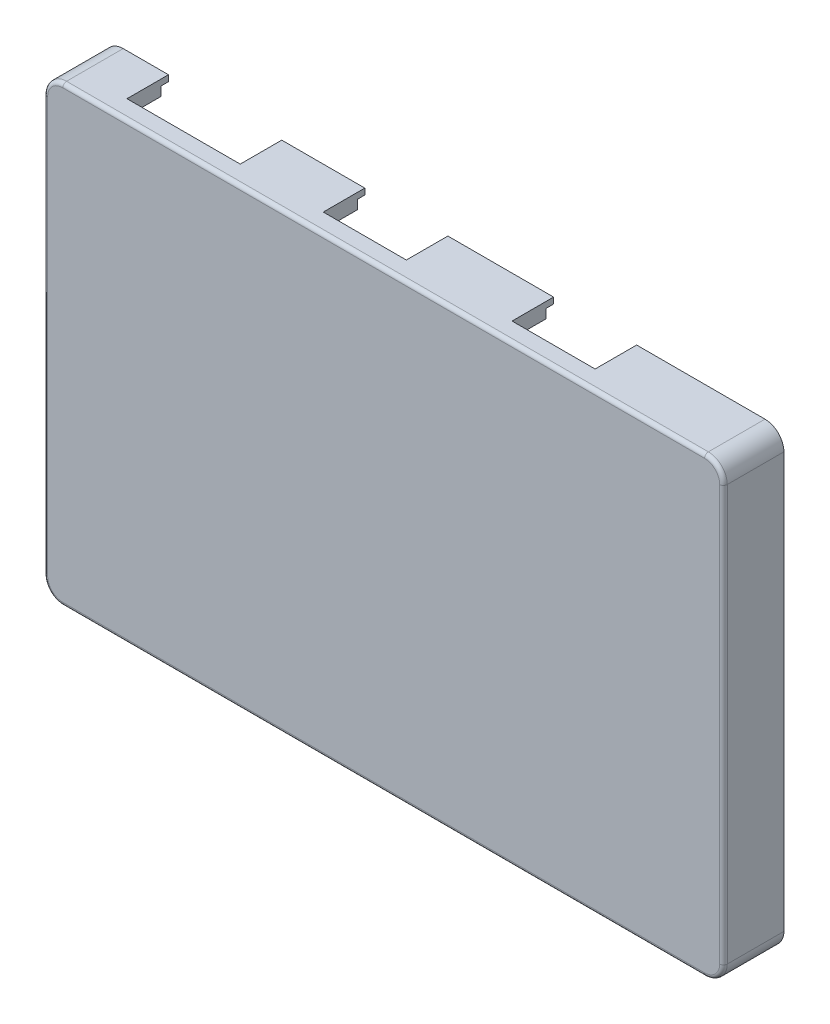
from build123d import *

# Parameters (mm, degrees)
SKETCH_1_W          = 90
SKETCH_1_H          = 60
EXTRUDE_1_DEPTH     = 2
SKETCH_2_W          = 50
SKETCH_2_H          = 35
EXTRUDE_2_DEPTH     = 1
SKETCH_3_W          = 14
SKETCH_3_H          = 13
EXTRUDE_3_DEPTH     = 10
SKETCH_4_W          = 10
SKETCH_4_H          = 12
EXTRUDE_4_DEPTH     = 5
SKETCH_5_W          = 26
SKETCH_5_H          = 26
EXTRUDE_5_DEPTH     = 1
SKETCH_6_W          = 10
SKETCH_6_H          = 10
EXTRUDE_6_DEPTH     = 7
SKETCH_7_W          = 43
SKETCH_7_H          = 18
EXTRUDE_7_DEPTH     = 1
SKETCH_8_W          = 2
SKETCH_8_H          = 60
EXTRUDE_8_DEPTH     = 5
SKETCH_9_W          = 88
SKETCH_9_H          = 2
EXTRUDE_9_DEPTH     = 5
SKETCH_10_W         = 2
SKETCH_10_H         = 58
EXTRUDE_10_DEPTH    = 5
SKETCH_11_W         = 86
SKETCH_11_H         = 2
EXTRUDE_11_DEPTH    = 5
SKETCH_12_W         = 0.8
SKETCH_12_H         = 60
EXTRUDE_12_DEPTH    = 1
SKETCH_13_W         = 89.2
SKETCH_13_H         = 0.8
EXTRUDE_13_DEPTH    = 1
SKETCH_14_W         = 0.8
SKETCH_14_H         = 59.2
EXTRUDE_14_DEPTH    = 1
SKETCH_15_W         = 88.4
SKETCH_15_H         = 0.8
EXTRUDE_15_DEPTH    = 1
SKETCH_16_W         = 11
SKETCH_16_H         = 8
CUT_EXTRUDE_2_DEPTH = 34
SKETCH_17_W         = 11
SKETCH_17_H         = 6
CUT_EXTRUDE_3_DEPTH = 34
SKETCH_18_W         = 15
SKETCH_18_H         = 11
CUT_EXTRUDE_4_DEPTH = 34
SKETCH_19_W         = 30
SKETCH_19_H         = 2
EXTRUDE_16_DEPTH    = 2
SKETCH_20_W         = 43
SKETCH_20_H         = 18
CUT_EXTRUDE_5_DEPTH = 1.5
SKETCH_21_W         = 26
SKETCH_21_H         = 26
CUT_EXTRUDE_6_DEPTH = 1.5
SKETCH_22_W         = 50
SKETCH_22_H         = 35
CUT_EXTRUDE_7_DEPTH = 1.5
FILLET_1_R          = 2.5
FILLET_2_R          = 2.5
FILLET_3_R          = 0.5


with BuildPart() as part:
    # Эскиз1 → Бобышка-Вытянуть1 (new body)
    with BuildSketch(Plane.XY):
        with Locations((11.347826087, -8.739130435)):
            Rectangle(SKETCH_1_W, SKETCH_1_H)
    extrude(amount=EXTRUDE_1_DEPTH)

    # Эскиз2 → Бобышка-Вытянуть2 (add)
    with BuildSketch(Plane(origin=(0, 0, 0), x_dir=(-1, 0, 0), z_dir=(0, 0, -1))):
        with Locations((3.652173913, 0.760869565)):
            Rectangle(SKETCH_2_W, SKETCH_2_H)
    extrude(amount=EXTRUDE_2_DEPTH)

    # Эскиз3 → Бобышка-Вытянуть3 (add)
    with BuildSketch(Plane(origin=(0, 0, -1), x_dir=(-1, 0, 0), z_dir=(0, 0, -1))):
        with Locations((17.652173913, 5.760869565)):
            Rectangle(SKETCH_3_W, SKETCH_3_H)
    extrude(amount=EXTRUDE_3_DEPTH)

    # Эскиз4 → Бобышка-Вытянуть4 (add)
    with BuildSketch(Plane(origin=(0, 0, -1), x_dir=(-1, 0, 0), z_dir=(0, 0, -1))):
        with Locations((-6.347826087, 15.260869565)):
            Rectangle(SKETCH_4_W, SKETCH_4_H)
    extrude(amount=EXTRUDE_4_DEPTH)

    # Эскиз5 → Бобышка-Вытянуть5 (add)
    with BuildSketch(Plane(origin=(0, 0, 0), x_dir=(-1, 0, 0), z_dir=(0, 0, -1))):
        with Locations((-38.347826087, 5.260869565)):
            Rectangle(SKETCH_5_W, SKETCH_5_H)
    extrude(amount=EXTRUDE_5_DEPTH)

    # Эскиз6 → Бобышка-Вытянуть6 (add)
    with BuildSketch(Plane(origin=(0, 0, -1), x_dir=(-1, 0, 0), z_dir=(0, 0, -1))):
        with Locations((-31.347826087, 14.260869565)):
            Rectangle(SKETCH_6_W, SKETCH_6_H)
    extrude(amount=EXTRUDE_6_DEPTH)

    # Эскиз7 → Бобышка-Вытянуть7 (add)
    with BuildSketch(Plane(origin=(0, 0, 0), x_dir=(-1, 0, 0), z_dir=(0, 0, -1))):
        with Locations((-14.606181905, -26.739130435)):
            Rectangle(SKETCH_7_W, SKETCH_7_H)
    extrude(amount=EXTRUDE_7_DEPTH)

    # Эскиз8 → Бобышка-Вытянуть8 (add)
    with BuildSketch(Plane(origin=(0, 0, 0), x_dir=(-1, 0, 0), z_dir=(0, 0, -1))):
        with Locations((-55.347826087, -8.739130435)):
            Rectangle(SKETCH_8_W, SKETCH_8_H)
    extrude(amount=EXTRUDE_8_DEPTH)

    # Эскиз9 → Бобышка-Вытянуть9 (add)
    with BuildSketch(Plane(origin=(0, 0, 0), x_dir=(-1, 0, 0), z_dir=(0, 0, -1))):
        with Locations((-10.347826087, -37.739130435)):
            Rectangle(SKETCH_9_W, SKETCH_9_H)
    extrude(amount=EXTRUDE_9_DEPTH)

    # Эскиз10 → Бобышка-Вытянуть10 (add)
    with BuildSketch(Plane(origin=(0, 0, 0), x_dir=(-1, 0, 0), z_dir=(0, 0, -1))):
        with Locations((32.652173913, -7.739130435)):
            Rectangle(SKETCH_10_W, SKETCH_10_H)
    extrude(amount=EXTRUDE_10_DEPTH)

    # Эскиз11 → Бобышка-Вытянуть11 (add)
    with BuildSketch(Plane(origin=(0, 0, 0), x_dir=(-1, 0, 0), z_dir=(0, 0, -1))):
        with Locations((-11.347826087, 20.260869565)):
            Rectangle(SKETCH_11_W, SKETCH_11_H)
    extrude(amount=EXTRUDE_11_DEPTH)

    # Эскиз12 → Бобышка-Вытянуть12 (add)
    with BuildSketch(Plane(origin=(0, 0, -5), x_dir=(-1, 0, 0), z_dir=(0, 0, -1))):
        with Locations((-55.947826087, -8.739130435)):
            Rectangle(SKETCH_12_W, SKETCH_12_H)
    extrude(amount=EXTRUDE_12_DEPTH)

    # Эскиз13 → Бобышка-Вытянуть13 (add)
    with BuildSketch(Plane(origin=(0, 0, -5), x_dir=(-1, 0, 0), z_dir=(0, 0, -1))):
        with Locations((-10.947826087, -38.339130435)):
            Rectangle(SKETCH_13_W, SKETCH_13_H)
    extrude(amount=EXTRUDE_13_DEPTH)

    # Эскиз14 → Бобышка-Вытянуть14 (add)
    with BuildSketch(Plane(origin=(0, 0, -5), x_dir=(-1, 0, 0), z_dir=(0, 0, -1))):
        with Locations((33.252173913, -8.339130435)):
            Rectangle(SKETCH_14_W, SKETCH_14_H)
    extrude(amount=EXTRUDE_14_DEPTH)

    # Эскиз15 → Бобышка-Вытянуть15 (add)
    with BuildSketch(Plane(origin=(0, 0, -5), x_dir=(-1, 0, 0), z_dir=(0, 0, -1))):
        with Locations((-11.347826087, 20.860869565)):
            Rectangle(SKETCH_15_W, SKETCH_15_H)
    extrude(amount=EXTRUDE_15_DEPTH)

    # Эскиз16 → Вырез-Вытянуть2 (cut)
    with BuildSketch(Plane.XZ.offset(-9.260869565)):
        with Locations((31.347826087, -4.5)):
            Rectangle(SKETCH_16_W, SKETCH_16_H)
    extrude(amount=-CUT_EXTRUDE_2_DEPTH, mode=Mode.SUBTRACT)

    # Эскиз17 → Вырез-Вытянуть3 (cut)
    with BuildSketch(Plane.XZ.offset(-9.260869565)):
        with Locations((6.347826087, -3.5)):
            Rectangle(SKETCH_17_W, SKETCH_17_H)
    extrude(amount=-CUT_EXTRUDE_3_DEPTH, mode=Mode.SUBTRACT)

    # Эскиз18 → Вырез-Вытянуть4 (cut)
    with BuildSketch(Plane.XZ.offset(0.739130435)):
        with Locations((-17.652173913, -6)):
            Rectangle(SKETCH_18_W, SKETCH_18_H)
    extrude(amount=-CUT_EXTRUDE_4_DEPTH, mode=Mode.SUBTRACT)

    # Эскиз19 → Бобышка-Вытянуть16 (add)
    with BuildSketch(Plane(origin=(0, 0, 0), x_dir=(-1, 0, 0), z_dir=(0, 0, -1))):
        with Locations((-39.347826087, -9.239130435)):
            Rectangle(SKETCH_19_W, SKETCH_19_H)
    extrude(amount=EXTRUDE_16_DEPTH)

    # Эскиз20 → Вырез-Вытянуть5 (cut)
    with BuildSketch(Plane(origin=(0, 0, -1), x_dir=(-1, 0, 0), z_dir=(0, 0, -1))):
        with Locations((-14.606181905, -26.739130435)):
            Rectangle(SKETCH_20_W, SKETCH_20_H)
    extrude(amount=-CUT_EXTRUDE_5_DEPTH, mode=Mode.SUBTRACT)

    # Эскиз21 → Вырез-Вытянуть6 (cut)
    with BuildSketch(Plane(origin=(0, 0, -1), x_dir=(-1, 0, 0), z_dir=(0, 0, -1))):
        with Locations((-38.347826087, 5.260869565)):
            Rectangle(SKETCH_21_W, SKETCH_21_H)
    extrude(amount=-CUT_EXTRUDE_6_DEPTH, mode=Mode.SUBTRACT)

    # Эскиз22 → Вырез-Вытянуть7 (cut)
    with BuildSketch(Plane(origin=(0, 0, -1), x_dir=(-1, 0, 0), z_dir=(0, 0, -1))):
        with Locations((3.652173913, 0.760869565)):
            Rectangle(SKETCH_22_W, SKETCH_22_H)
    extrude(amount=-CUT_EXTRUDE_7_DEPTH, mode=Mode.SUBTRACT)

    # Скругление1
    fillet_1_edges = [part.edges().sort_by_distance(p)[0] for p in [
        (54.347826087, -36.739130435, -2.5),
        (-31.652173913, -36.739130435, -2.5),
        (54.347826087, 19.260869565, -2.5),
        (-31.652173913, 19.260869565, -2.5),
        (-33.652173913, 21.260869565, -2),
        (56.347826087, 21.260869565, -2),
        (56.347826087, -38.739130435, -2),
        (-33.652173913, -38.739130435, -2),
    ]]
    fillet(fillet_1_edges, radius=FILLET_1_R)

    # Скругление2
    fillet_2_edges = [part.edges().sort_by_distance(p)[0] for p in [
        (55.547826087, -37.939130435, -5.5),
        (-32.852173913, -37.939130435, -5.5),
        (55.547826087, 20.460869565, -5.5),
        (-32.852173913, 20.460869565, -5.5),
    ]]
    fillet(fillet_2_edges, radius=FILLET_2_R)

    # Скругление3
    fillet_3_edges = [part.edges().sort_by_distance(p)[0] for p in [
        (11.347826087, 21.260869565, 2),
        (56.347826087, -8.739130435, 2),
        (-33.652173913, -8.739130435, 2),
        (11.347826087, -38.739130435, 2),
        (-32.919940866, 20.528636518, 2),
        (-32.919940866, -38.006897388, 2),
        (55.61559304, -38.006897388, 2),
        (55.61559304, 20.528636518, 2),
    ]]
    fillet(fillet_3_edges, radius=FILLET_3_R)


solid = part.part
